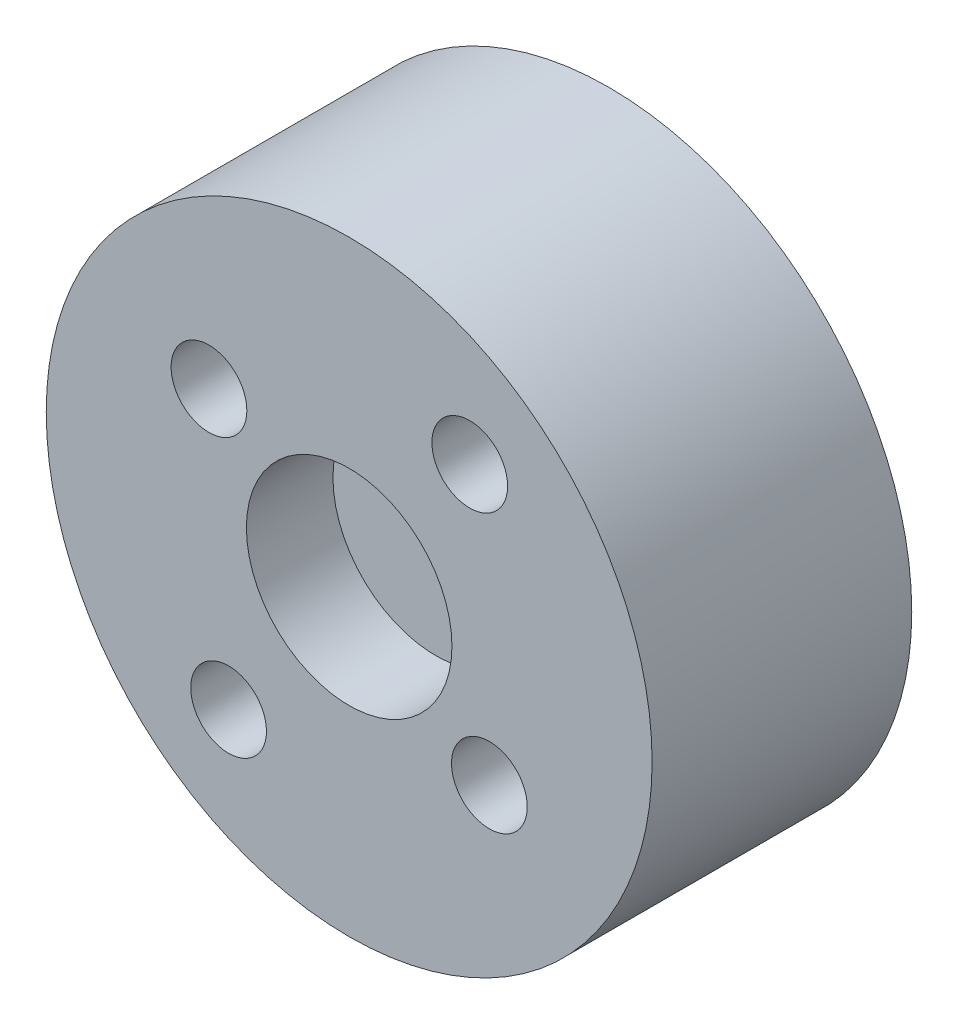
from build123d import *

# Parameters (mm, degrees)
SKETCH2_R           = 14
BOSS_EXTRUDE1_DEPTH = 12
SKETCH3_R           = 1.75
CUT_EXTRUDE1_DEPTH  = 13
SKETCH4_R           = 4.75
CUT_EXTRUDE2_DEPTH  = 4


with BuildPart() as part:
    # Sketch2 → Boss-Extrude1 (new body)
    with BuildSketch(Plane(origin=(0, 0, 12), x_dir=(-1, 0, 0), z_dir=(0, 0, -1))):
        Circle(SKETCH2_R)
    extrude(amount=BOSS_EXTRUDE1_DEPTH)

    # Sketch3 → Cut-Extrude1 (cut, through all)
    with BuildSketch(Plane.XY.offset(12)):
        with Locations((-6.479247663, 4.692477993)):
            Circle(SKETCH3_R)
        with Locations((5.572317617, 7.6941066)):
            Circle(SKETCH3_R)
        with Locations((6.479247663, -4.692477993)):
            Circle(SKETCH3_R)
        with Locations((-5.572317617, -7.6941066)):
            Circle(SKETCH3_R)
    extrude(amount=-CUT_EXTRUDE1_DEPTH, mode=Mode.SUBTRACT)

    # Sketch4 → Cut-Extrude2 (cut)
    with BuildSketch(Plane.XY.offset(12)):
        Circle(SKETCH4_R)
    extrude(amount=-CUT_EXTRUDE2_DEPTH, mode=Mode.SUBTRACT)


solid = part.part
